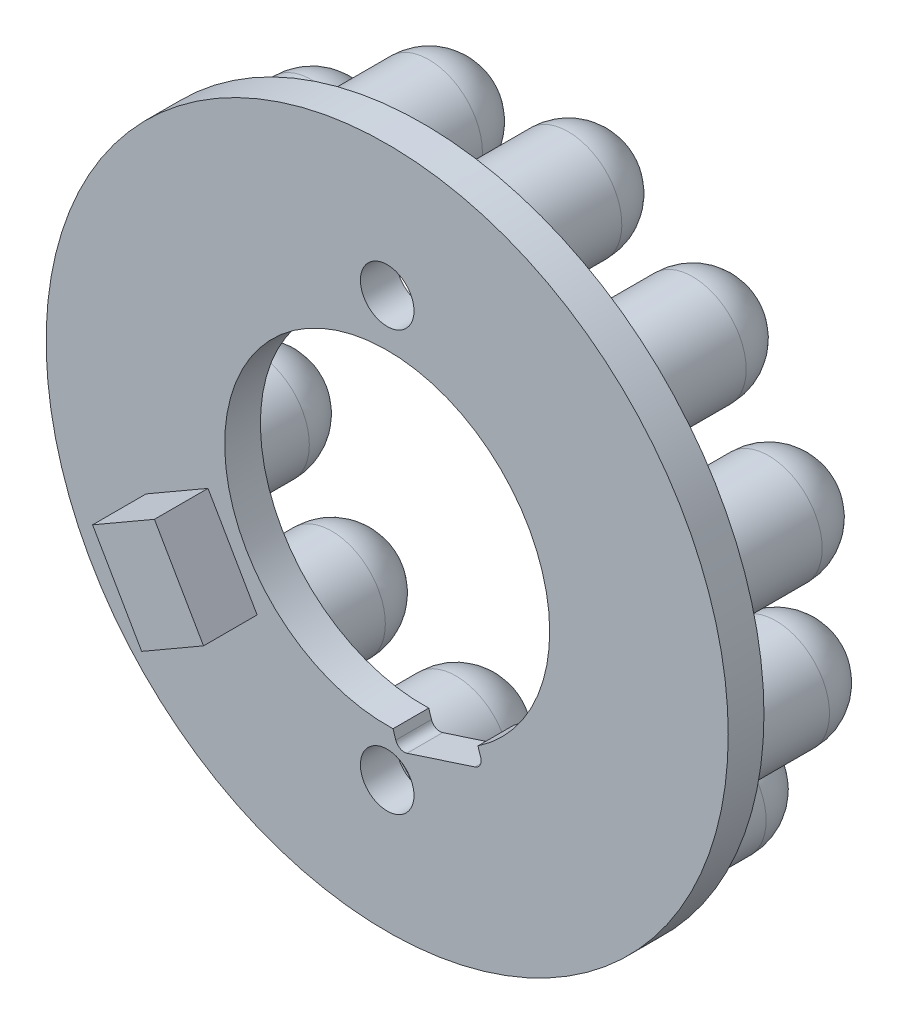
from build123d import *

# Parameters (mm, degrees)
SKETCH1_R           = 19.1
SKETCH1_R_2         = 1.5
BOSS_EXTRUDE1_DEPTH = 2
FILLET1_R           = 0.5
BOSS_EXTRUDE2_DEPTH = 3
SKETCH4_R           = 3
BOSS_EXTRUDE3_DEPTH = 5
CIRPATTERN1_COUNT   = 12


with BuildPart() as part:
    # Sketch1 → Boss-Extrude1 (new body)
    with BuildSketch(Plane.XY):
        Circle(SKETCH1_R)
        with Locations((0, -11.75)):
            Circle(SKETCH1_R_2, mode=Mode.SUBTRACT)
        with BuildLine():
            Line((0.635230259, -10.045207653), (0.326213264, -9.094151137))
            ThreePointArc((0.326213264, -9.094151137), (-6.548990025, 6.318285341), (9.1, 0))
            ThreePointArc((9.1, 0), (8.032795659, -4.276002093), (5.081495846, -7.549066165))
            Line((5.081495846, -7.549066165), (5.39051284, -8.500122682))
            Line((5.39051284, -8.500122682), (0.635230259, -10.045207653))
        make_face(mode=Mode.SUBTRACT)
        with Locations((0, 11.75)):
            Circle(SKETCH1_R_2, mode=Mode.SUBTRACT)
    extrude(amount=BOSS_EXTRUDE1_DEPTH)

    # Fillet1
    fillet1_edges = [part.edges().sort_by_distance(p)[0] for p in [
        (0.635230259, -10.045207653, 1),
        (5.39051284, -8.500122682, 1),
    ]]
    fillet(fillet1_edges, radius=FILLET1_R)

    # Sketch3 → Boss-Extrude2 (add)
    with BuildSketch(Plane.XY.offset(2)):
        Polygon((-10.035254038, -2.61843014), (-13.499355653, -4.61843014), (-10.749355653, -9.38156986), (-7.285254038, -7.38156986), align=None)
    extrude(amount=BOSS_EXTRUDE2_DEPTH)

    # Sketch4 → Boss-Extrude3 (add)
    with BuildSketch(Plane(origin=(0, 0, 0), x_dir=(-1, 0, 0), z_dir=(0, 0, -1))):
        with Locations((-4.666156615, -14.360953396)):
            Circle(SKETCH4_R)
    boss_extrude3 = extrude(amount=BOSS_EXTRUDE3_DEPTH)

    # Sketch5 → Revolve1 (revolve)
    with BuildSketch(Plane(origin=(0, 0, -5), x_dir=(-1, 0, 0), z_dir=(0, 0, -1))):
        with BuildLine():
            Line((-4.666156615, -11.360953396), (-4.666156615, -17.360953396))
            ThreePointArc((-4.666156615, -17.360953396), (-1.666156615, -14.360953396), (-4.666156615, -11.360953396))
        make_face()
    revolve1 = revolve(axis=Axis((4.666156615, -11.360953396, -5), (0, -1, 0)))

    # CirPattern1: Boss-Extrude3, Revolve1 ×12 about axis
    cirpattern1_axis = Axis((0, 0, 0), (0, 0, 1))
    for i in range(1, CIRPATTERN1_COUNT):
        add(boss_extrude3.rotate(cirpattern1_axis, i * 360 / CIRPATTERN1_COUNT))
        add(revolve1.rotate(cirpattern1_axis, i * 360 / CIRPATTERN1_COUNT))


solid = part.part
